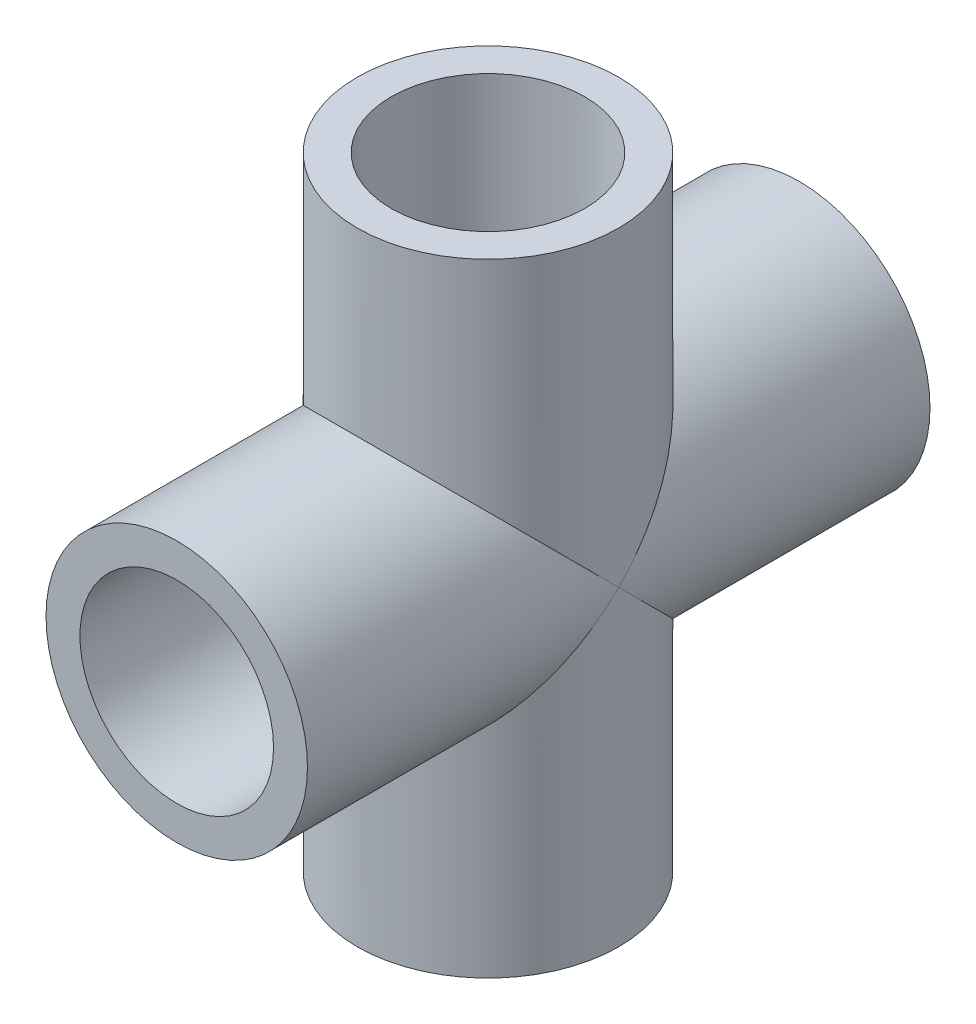
from build123d import *

# Parameters (mm, degrees)
SKETCH1_R               = 10.668
SKETCH1_R_2             = 7.8994
BOSS_EXTRUDE1_DEPTH     = 50.8
SKETCH2_R               = 10.668
SKETCH2_R_2             = 7.8994
BOSS_EXTRUDE2_DEPTH     = 25.4
SKETCH3_R               = 7.8994
CUT_EXTRUDE1_DEPTH      = 51.8000001
SKETCH4_R               = 7.8994
CUT_EXTRUDE2_DEPTH      = 1.0000001
CUT_EXTRUDE2_DEPTH_BACK = 51.8000001


with BuildPart() as part:
    # Sketch1 → Boss-Extrude1 (new body)
    with BuildSketch(Plane.XY):
        Circle(SKETCH1_R)
        Circle(SKETCH1_R_2, mode=Mode.SUBTRACT)
    extrude(amount=BOSS_EXTRUDE1_DEPTH)

    # Sketch2 → Boss-Extrude2 (add, symmetric)
    with BuildSketch(Plane(origin=(0, 0, 0), x_dir=(1, 0, 0), z_dir=(0, 1, 0))):
        with Locations((0, -25.4)):
            Circle(SKETCH2_R)
        with Locations((0, -25.4)):
            Circle(SKETCH2_R_2, mode=Mode.SUBTRACT)
    extrude(amount=BOSS_EXTRUDE2_DEPTH, both=True)

    # Sketch3 → Cut-Extrude1 (cut, through all)
    with BuildSketch(Plane.XY.offset(50.8)):
        Circle(SKETCH3_R)
    extrude(amount=-CUT_EXTRUDE1_DEPTH, mode=Mode.SUBTRACT)

    # Sketch4 → Cut-Extrude2 (cut, two sides)
    with BuildSketch(Plane(origin=(0, 25.4, 0), x_dir=(1, 0, 0), z_dir=(0, 1, 0))) as cut_extrude2_sk:
        with Locations((0, -25.4)):
            Circle(SKETCH4_R)
    extrude(amount=CUT_EXTRUDE2_DEPTH, mode=Mode.SUBTRACT)
    extrude(cut_extrude2_sk.sketch, amount=-CUT_EXTRUDE2_DEPTH_BACK, mode=Mode.SUBTRACT)


solid = part.part
